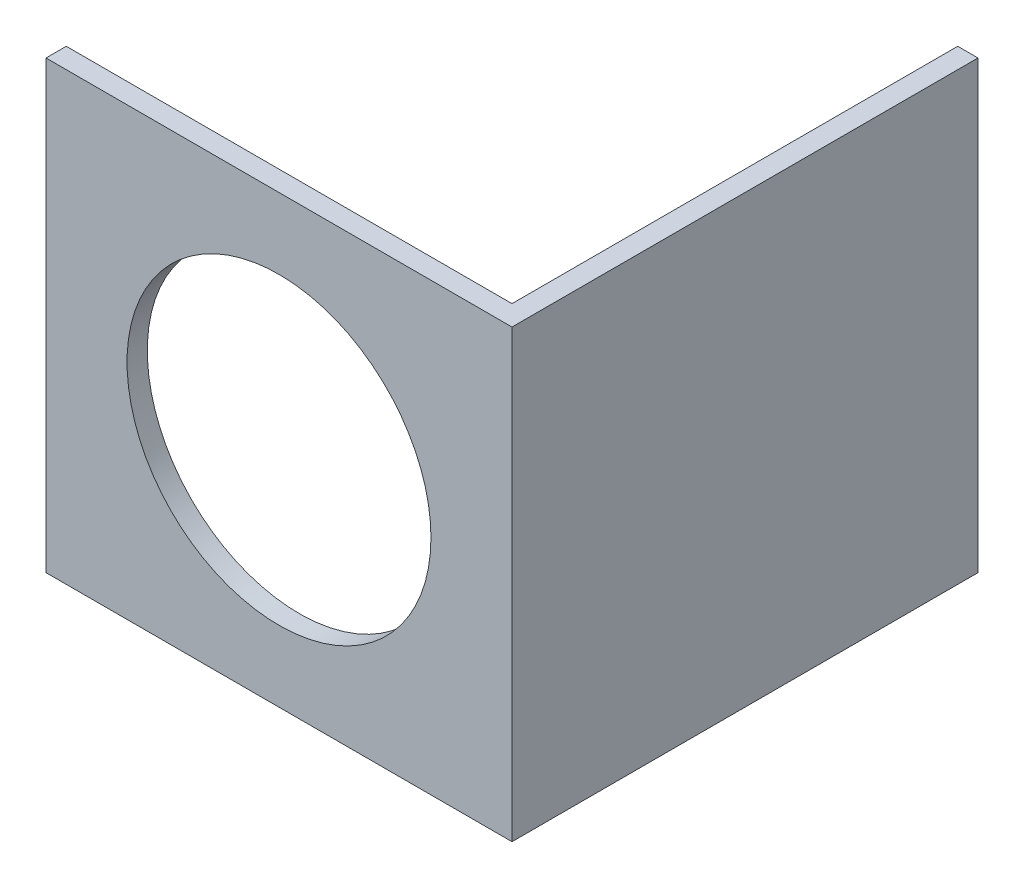
from build123d import *

# Parameters (mm, degrees)
BOSS_EXTRUDE1_DEPTH = 44
CUT_EXTRUDE1_DEPTH  = 44


with BuildPart() as part:
    # Sketch1 → Boss-Extrude1 (new body)
    with BuildSketch(Plane(origin=(0, 0, 0), x_dir=(1, 0, 0), z_dir=(0, 1, 0))):
        Polygon((-9.579875479, -19.511993177), (36.420124521, -19.511993177), (36.420124521, 26.488006823), (34.420124521, 26.488006823), (34.420124521, -17.511993177), (-9.579875479, -17.511993177), align=None)
    extrude(amount=BOSS_EXTRUDE1_DEPTH)

    # Sketch2 → Cut-Extrude1 (cut)
    with BuildSketch(Plane.XY.offset(19.511993177)):
        with BuildLine():
            ThreePointArc((28.420124521, 22), (13.420124521, 37), (-1.579875479, 22))
            Line((-1.579875479, 22), (28.420124521, 22))
        make_face()
        with BuildLine():
            Line((28.420124521, 22), (-1.579875479, 22))
            ThreePointArc((-1.579875479, 22), (13.420124521, 7), (28.420124521, 22))
        make_face()
    extrude(amount=-CUT_EXTRUDE1_DEPTH, mode=Mode.SUBTRACT)


solid = part.part
